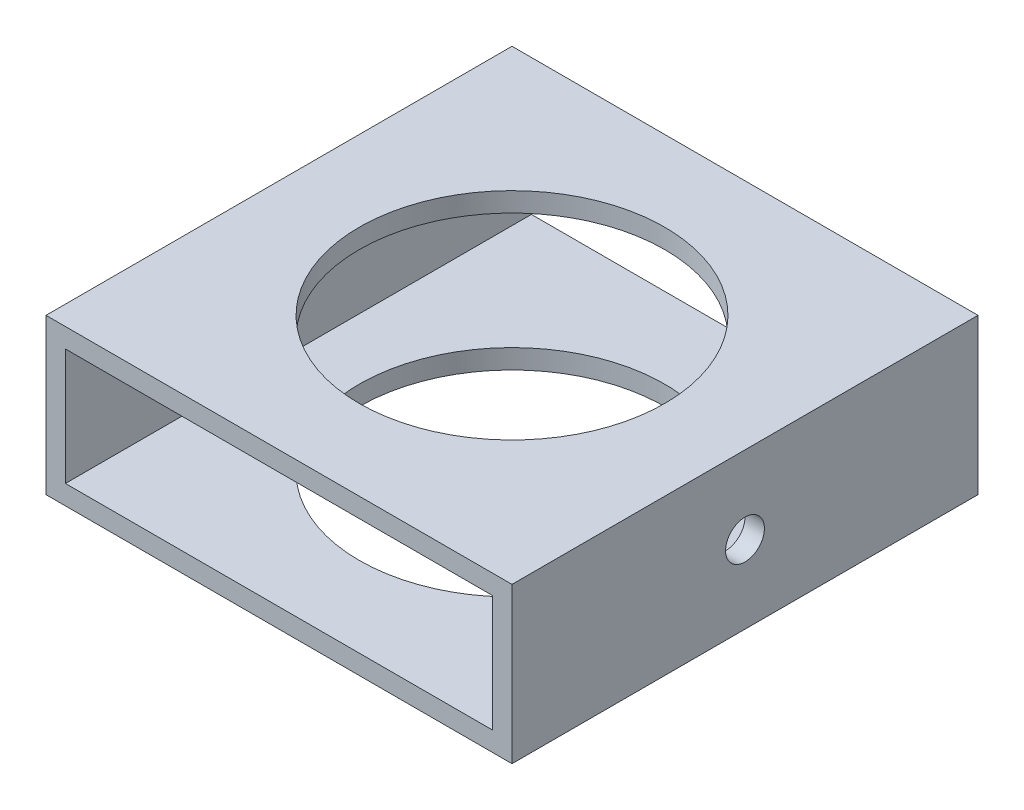
from build123d import *

# Parameters (mm, degrees)
SKETCH1_W           = 76.2
SKETCH1_H           = 25.4
SKETCH1_W_2         = 69.85
SKETCH1_H_2         = 19.05
EXTRUDE_THIN1_DEPTH = 38.1
SKETCH2_R           = 3.175
CUT_EXTRUDE1_DEPTH  = 77.2
SKETCH3_R           = 24.97201
CUT_EXTRUDE2_DEPTH  = 26.4


with BuildPart() as part:
    # Sketch1 → Extrude-Thin1 (new body, symmetric)
    with BuildSketch(Plane.XY):
        Rectangle(SKETCH1_W, SKETCH1_H)
        Rectangle(SKETCH1_W_2, SKETCH1_H_2, mode=Mode.SUBTRACT)
    extrude(amount=EXTRUDE_THIN1_DEPTH, both=True)

    # Sketch2 → Cut-Extrude1 (cut, through all)
    with BuildSketch(Plane.ZY.offset(38.1)):
        Circle(SKETCH2_R)
    extrude(amount=-CUT_EXTRUDE1_DEPTH, mode=Mode.SUBTRACT)

    # Sketch3 → Cut-Extrude2 (cut, through all)
    with BuildSketch(Plane(origin=(0, 12.7, 0), x_dir=(1, 0, 0), z_dir=(0, 1, 0))):
        Circle(SKETCH3_R)
    extrude(amount=-CUT_EXTRUDE2_DEPTH, mode=Mode.SUBTRACT)


solid = part.part
